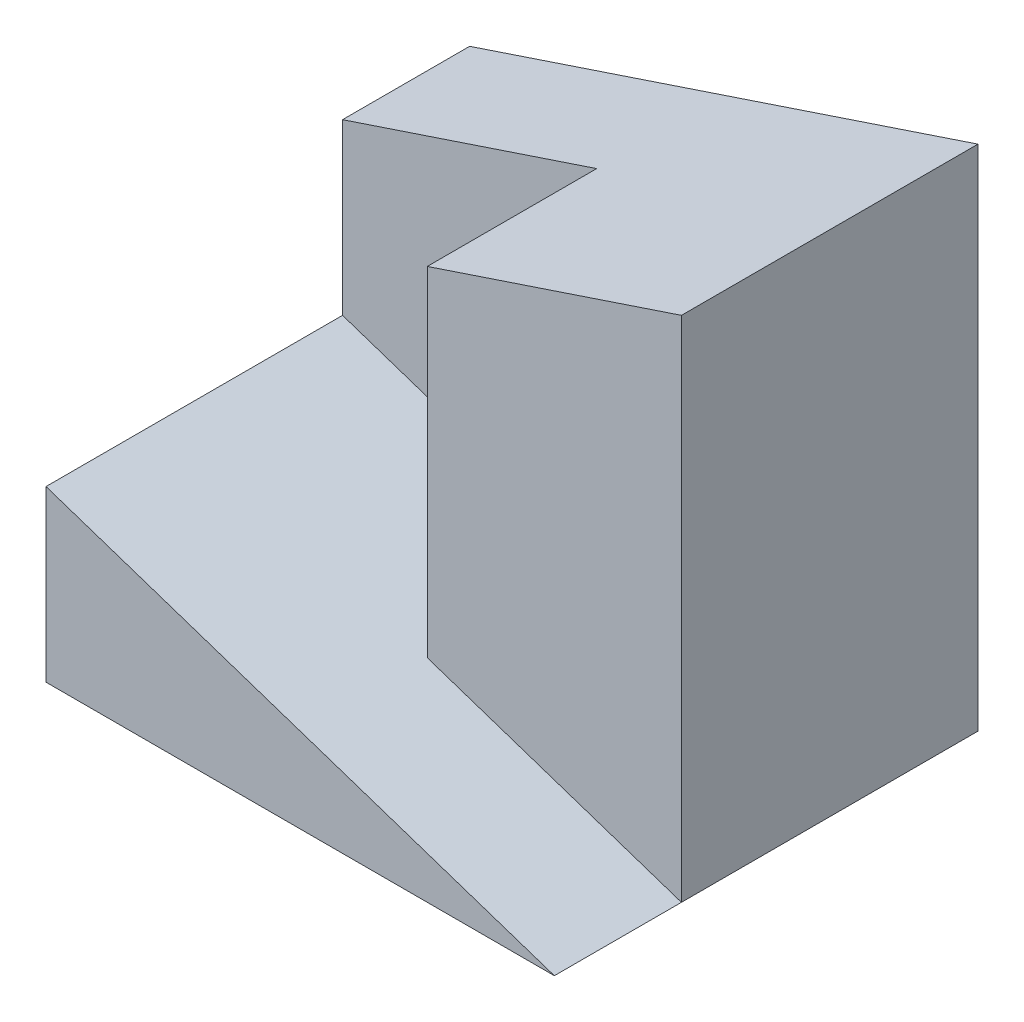
from build123d import *

# Parameters (mm, degrees)
SKETCH1_W           = 6
SKETCH1_H           = 5
BOSS_EXTRUDE1_DEPTH = 6
CUT_EXTRUDE1_DEPTH  = 3.5
CUT_EXTRUDE2_DEPTH  = 1.5
CUT_EXTRUDE3_DEPTH  = 11.5


with BuildPart() as part:
    # Sketch1 → Boss-Extrude1 (new body)
    with BuildSketch(Plane(origin=(0, 0, 0), x_dir=(1, 0, 0), z_dir=(0, 1, 0))):
        Rectangle(SKETCH1_W, SKETCH1_H)
    extrude(amount=BOSS_EXTRUDE1_DEPTH)

    # Sketch2 → Cut-Extrude1 (cut)
    with BuildSketch(Plane.XY.offset(2.5)):
        Polygon((-3, 6), (-3, 2), (0, 1), (0, 6), align=None)
    extrude(amount=-CUT_EXTRUDE1_DEPTH, mode=Mode.SUBTRACT)

    # Sketch3 → Cut-Extrude2 (cut)
    with BuildSketch(Plane.XY.offset(2.5)):
        Polygon((0, 1), (3, 0), (3, 6), (0, 6), align=None)
    extrude(amount=-CUT_EXTRUDE2_DEPTH, mode=Mode.SUBTRACT)

    # Sketch4 → Cut-Extrude3 (cut)
    with BuildSketch(Plane.XY.offset(1)):
        Polygon((3, 6), (-3, 4), (-3, 6), align=None)
    extrude(amount=-CUT_EXTRUDE3_DEPTH, mode=Mode.SUBTRACT)


solid = part.part
